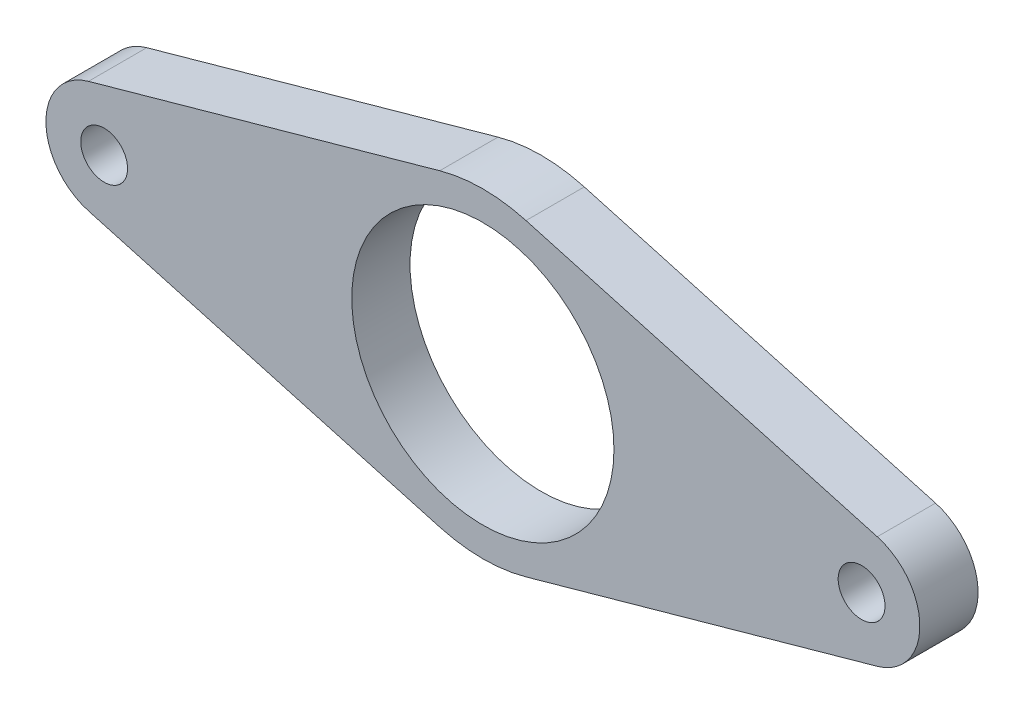
from build123d import *

# Parameters (mm, degrees)
SKETCH1_R           = 2.5527
SKETCH1_R_2         = 14.2875
BOSS_EXTRUDE1_DEPTH = 6.35


with BuildPart() as part:
    # Sketch1 → Boss-Extrude1 (new body)
    with BuildSketch(Plane.XY):
        with BuildLine():
            Line((42.984615385, 6.115530659), (4.701442308, 16.817709311))
            ThreePointArc((4.701442308, 16.817709311), (0, 17.4625), (-4.701442308, 16.817709311))
            Line((-4.701442308, 16.817709311), (-42.984615385, 6.115530659))
            ThreePointArc((-42.984615385, 6.115530659), (-47.625, 0), (-42.984615385, -6.115530659))
            Line((-42.984615385, -6.115530659), (-4.701442308, -16.817709311))
            ThreePointArc((-4.701442308, -16.817709311), (0, -17.4625), (4.701442308, -16.817709311))
            Line((4.701442308, -16.817709311), (42.984615385, -6.115530659))
            ThreePointArc((42.984615385, -6.115530659), (47.625, 0), (42.984615385, 6.115530659))
        make_face()
        with Locations((-41.275, 0)):
            Circle(SKETCH1_R, mode=Mode.SUBTRACT)
        with Locations((41.275, 0)):
            Circle(SKETCH1_R, mode=Mode.SUBTRACT)
        Circle(SKETCH1_R_2, mode=Mode.SUBTRACT)
    extrude(amount=BOSS_EXTRUDE1_DEPTH)


solid = part.part
